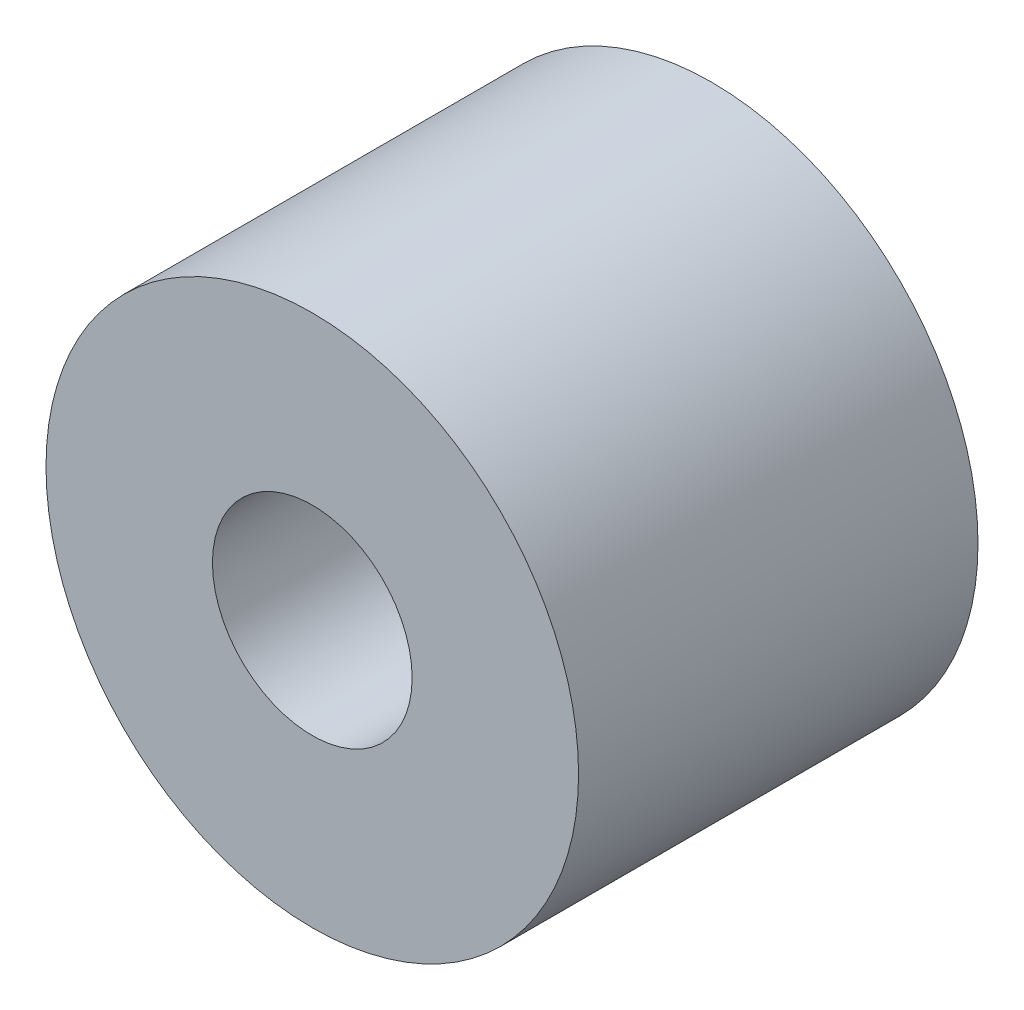
from build123d import *

# Parameters (mm, degrees)
SKETCH1_R           = 60
SKETCH1_R_2         = 22.5
BOSS_EXTRUDE1_DEPTH = 90


with BuildPart() as part:
    # Sketch1 → Boss-Extrude1 (new body)
    with BuildSketch(Plane.XY):
        Circle(SKETCH1_R)
        Circle(SKETCH1_R_2, mode=Mode.SUBTRACT)
    extrude(amount=BOSS_EXTRUDE1_DEPTH)


solid = part.part
